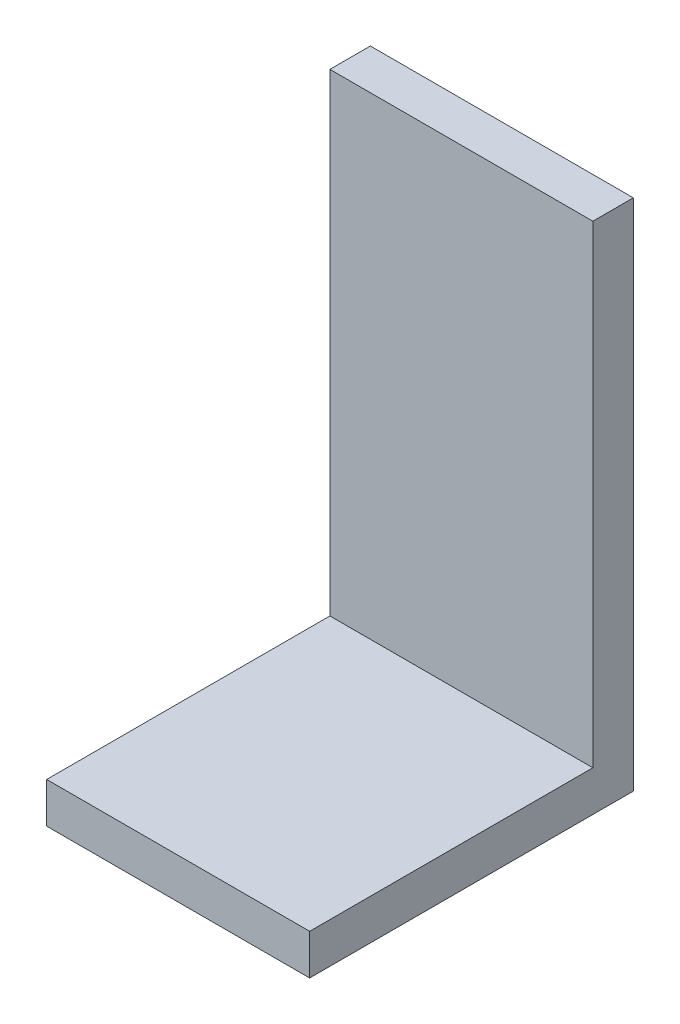
from build123d import *

# Parameters (mm, degrees)
SKETCH1_W           = 13
SKETCH1_H           = 16
BOSS_EXTRUDE1_DEPTH = 2
SKETCH2_W           = 13
SKETCH2_H           = 2
BOSS_EXTRUDE2_DEPTH = 23.4


with BuildPart() as part:
    # Sketch1 → Boss-Extrude1 (new body)
    with BuildSketch(Plane(origin=(0, 0, 0), x_dir=(1, 0, 0), z_dir=(0, 1, 0))):
        with Locations((-41.144444444, 29.688888889)):
            Rectangle(SKETCH1_W, SKETCH1_H)
    extrude(amount=BOSS_EXTRUDE1_DEPTH)

    # Sketch2 → Boss-Extrude2 (add)
    with BuildSketch(Plane(origin=(0, 2, 0), x_dir=(1, 0, 0), z_dir=(0, 1, 0))):
        with Locations((-41.144444444, 36.688888889)):
            Rectangle(SKETCH2_W, SKETCH2_H)
    extrude(amount=BOSS_EXTRUDE2_DEPTH)


solid = part.part
